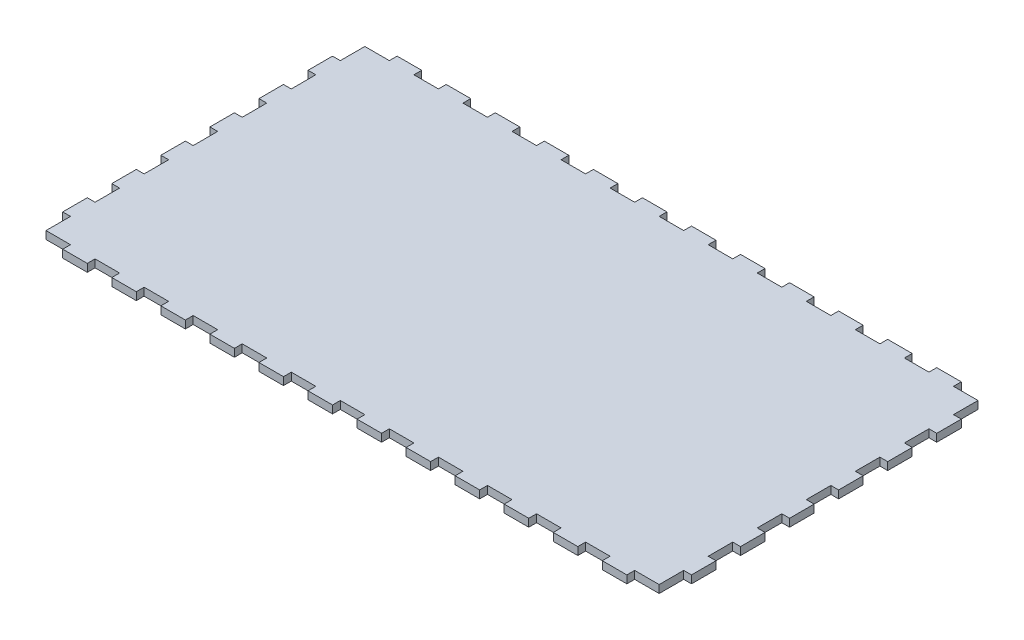
from build123d import *

# Parameters (mm, degrees)
ESQUISSE1_W                = 250
ESQUISSE1_H                = 130
BOSS_EXTRU_1_DEPTH         = 3.175
ESQUISSE2_W                = 10
ESQUISSE2_H                = 3.175
BOSS_EXTRU_2_DEPTH         = 3.175
R_P_TITION_LIN_AIRE1_COUNT = 12
R_P_TITION_LIN_AIRE1_PITCH = 20
ESQUISSE3_W                = 3.175
ESQUISSE3_H                = 10
BOSS_EXTRU_3_DEPTH         = 3.175
R_P_TITION_LIN_AIRE2_COUNT = 6
R_P_TITION_LIN_AIRE2_PITCH = 20


with BuildPart() as part:
    # Esquisse1 → Boss.-Extru.1 (new body)
    with BuildSketch(Plane(origin=(0, 0, 0), x_dir=(1, 0, 0), z_dir=(0, 1, 0))):
        with Locations((125, 65)):
            Rectangle(ESQUISSE1_W, ESQUISSE1_H)
    extrude(amount=BOSS_EXTRU_1_DEPTH)

    # Esquisse2 → Boss.-Extru.2 (add)
    with BuildSketch(Plane(origin=(0, 3.175, 0), x_dir=(1, 0, 0), z_dir=(0, 1, 0))):
        with Locations((15, 131.5875)):
            Rectangle(ESQUISSE2_W, ESQUISSE2_H)
        with Locations((15, -1.5875)):
            Rectangle(ESQUISSE2_W, ESQUISSE2_H)
    boss_extru_2 = extrude(amount=-BOSS_EXTRU_2_DEPTH)

    # Répétition linéaire1: Boss.-Extru.2 ×12
    with Locations(*[(i * R_P_TITION_LIN_AIRE1_PITCH, 0, 0) for i in range(1, R_P_TITION_LIN_AIRE1_COUNT)]):
        add(boss_extru_2)

    # Esquisse3 → Boss.-Extru.3 (add)
    with BuildSketch(Plane(origin=(0, 3.175, 0), x_dir=(1, 0, 0), z_dir=(0, 1, 0))):
        with Locations((251.5875, 115)):
            Rectangle(ESQUISSE3_W, ESQUISSE3_H)
        with Locations((-1.5875, 115)):
            Rectangle(ESQUISSE3_W, ESQUISSE3_H)
    boss_extru_3 = extrude(amount=-BOSS_EXTRU_3_DEPTH)

    # Répétition linéaire2: Boss.-Extru.3 ×6
    with Locations(*[(0, 0, i * R_P_TITION_LIN_AIRE2_PITCH) for i in range(1, R_P_TITION_LIN_AIRE2_COUNT)]):
        add(boss_extru_3)


solid = part.part
